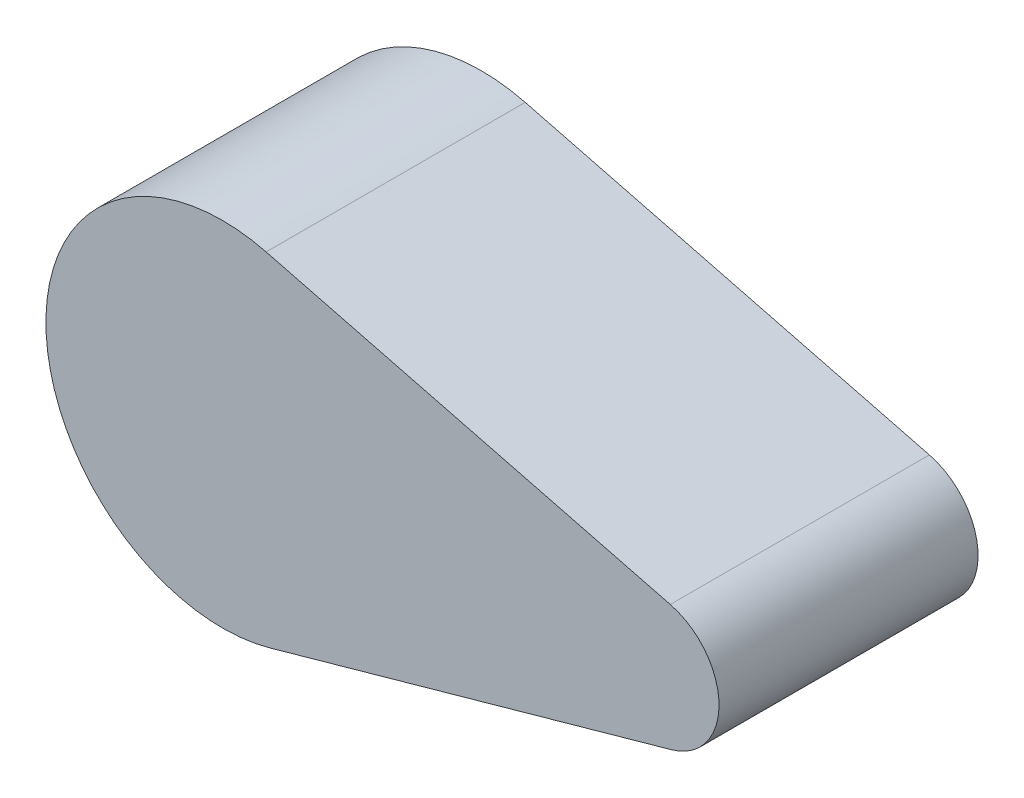
from build123d import *

# Parameters (mm, degrees)
BOSS_EXTRUDE1_DEPTH = 152.4


with BuildPart() as part:
    # Sketch1 → Boss-Extrude1 (new body)
    with BuildSketch(Plane.XY):
        with BuildLine():
            Line((28.045443959, -99.985678365), (264.289724394, -33.720430823))
            ThreePointArc((264.289724394, -33.720430823), (292.097406561, 3.408320629), (263.43094438, 39.878107))
            Line((263.43094438, 39.878107), (25.704772254, 100.612859458))
            ThreePointArc((25.704772254, 100.612859458), (-103.837444017, -1.211620831), (28.045443959, -99.985678365))
        make_face()
    extrude(amount=-BOSS_EXTRUDE1_DEPTH)


solid = part.part
